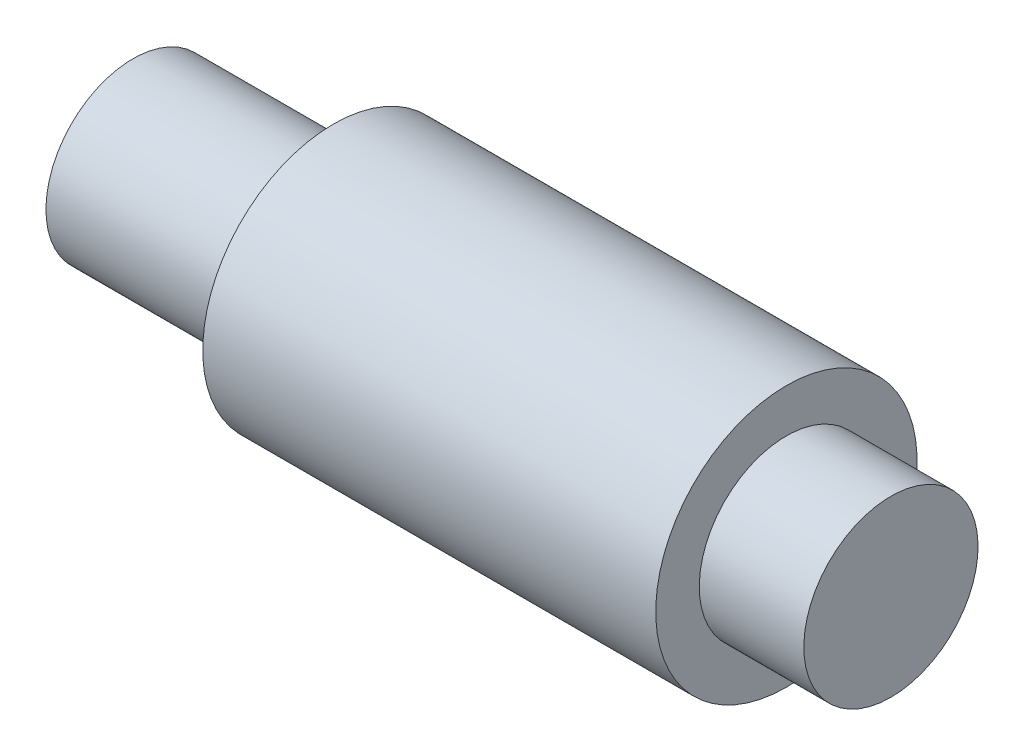
from build123d import *


with BuildPart() as part:
    # Sketch1 → Revolve1 (revolve)
    with BuildSketch(Plane.XY):
        Polygon((0, 0), (0, -10), (87, -10), (87, 0), (75, 0), (75, 5), (23, 5), (23, 0), align=None)
    revolve(axis=Axis((0, -10, 0), (1, 0, 0)))


solid = part.part
